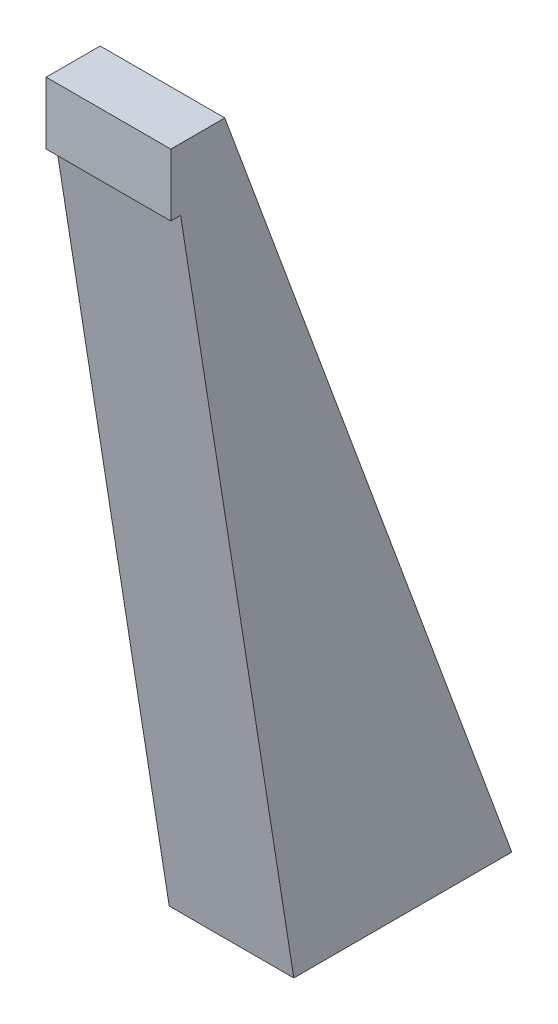
from build123d import *

# Parameters (mm, degrees)
BOSS_EXTRUDE1_DEPTH = 60
SKETCH2_W           = 26
SKETCH2_H           = 30
BOSS_EXTRUDE2_DEPTH = 60


with BuildPart() as part:
    # Sketch1 → Boss-Extrude1 (new body)
    with BuildSketch(Plane(origin=(0, 0, 0), x_dir=(0, 0, -1), z_dir=(1, 0, 0))):
        Polygon((0, 0), (-59.234177215, 375.354915047), (-33.234177215, 375.354915047), (105, 0), align=None)
    extrude(amount=BOSS_EXTRUDE1_DEPTH)

    # Sketch2 → Boss-Extrude2 (add)
    with BuildSketch(Plane.ZY):
        with Locations((46.234177215, 360.354915047)):
            Rectangle(SKETCH2_W, SKETCH2_H)
    extrude(amount=-BOSS_EXTRUDE2_DEPTH)


solid = part.part
